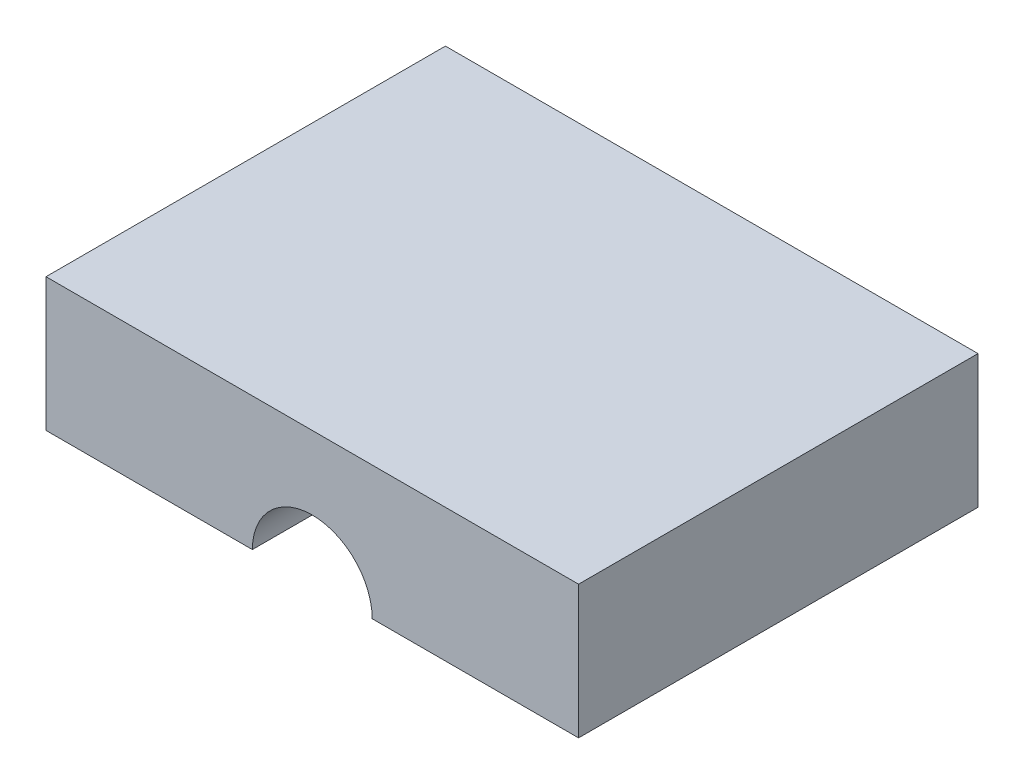
from build123d import *

# Parameters (mm, degrees)
ESQUISSE1_W             = 20
ESQUISSE1_H             = 30
BOSS_EXTRU_1_DEPTH      = 10
ESQUISSE2_R             = 6
BOSS_EXTRU_2_DEPTH      = 40
ESQUISSE3_W             = 40
ESQUISSE3_H             = 30
BOSS_EXTRU_3_DEPTH      = 15
ESQUISSE4_R             = 4.5
ENL_V_MAT_EXTRU_1_DEPTH = 55
ENL_V_MAT_EXTRU_3_DEPTH = 55
ESQUISSE8_W             = 40.266643215
ESQUISSE8_H             = 36.212285802
ENL_V_MAT_EXTRU_4_DEPTH = 55


with BuildPart() as part:
    # Esquisse1 → Boss.-Extru.1 (new body)
    with BuildSketch(Plane.XY):
        with Locations((-10, 15)):
            Rectangle(ESQUISSE1_W, ESQUISSE1_H)
    extrude(amount=BOSS_EXTRU_1_DEPTH)

    # Esquisse2 → Boss.-Extru.2 (add)
    with BuildSketch(Plane.XY.offset(10)):
        with Locations((-10, 18)):
            Circle(ESQUISSE2_R)
    extrude(amount=BOSS_EXTRU_2_DEPTH)

    # Esquisse3 → Boss.-Extru.3 (add)
    with BuildSketch(Plane.XZ):
        with Locations((-10, 15)):
            Rectangle(ESQUISSE3_W, ESQUISSE3_H)
    extrude(amount=BOSS_EXTRU_3_DEPTH)

    # Esquisse4 → Enlèv. mat.-Extru.1 (cut)
    with BuildSketch(Plane(origin=(0, 0, 0), x_dir=(-1, 0, 0), z_dir=(0, 0, -1))):
        with Locations((10, -15)):
            Circle(ESQUISSE4_R)
    extrude(amount=-ENL_V_MAT_EXTRU_1_DEPTH, mode=Mode.SUBTRACT)

    # Esquisse5 → Enlèv. mat.-Extru.3 (cut)
    with BuildSketch(Plane(origin=(0, 0, 0), x_dir=(-1, 0, 0), z_dir=(0, 0, -1))):
        with BuildLine():
            Line((30, 0), (25, 0))
            ThreePointArc((25, 0), (28.535533906, -1.464466094), (30, -5))
            Line((30, -5), (30, 0))
        make_face()
        with BuildLine():
            Line((-10, 0), (-10, -5))
            ThreePointArc((-10, -5), (-8.535533906, -1.464466094), (-5, 0))
            Line((-5, 0), (-10, 0))
        make_face()
    extrude(amount=-ENL_V_MAT_EXTRU_3_DEPTH, mode=Mode.SUBTRACT)

    # Esquisse8 → Enlèv. mat.-Extru.4 (cut)
    with BuildSketch(Plane(origin=(0, 0, 0), x_dir=(-1, 0, 0), z_dir=(0, 0, -1))):
        with Locations((10.133321608, 13.106142901)):
            Rectangle(ESQUISSE8_W, ESQUISSE8_H)
    extrude(amount=-ENL_V_MAT_EXTRU_4_DEPTH, mode=Mode.SUBTRACT)


solid = part.part
